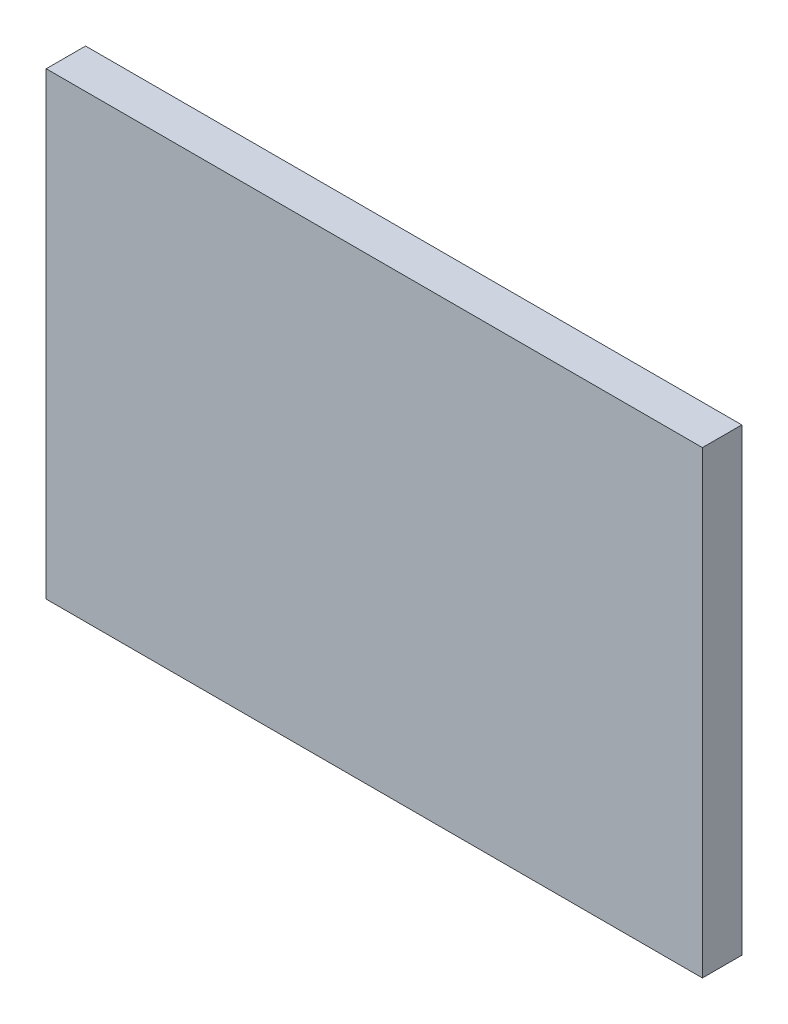
from build123d import *

# Parameters (mm, degrees)
SKETCH1_W           = 50
SKETCH1_H           = 35
BOSS_EXTRUDE1_DEPTH = 3


with BuildPart() as part:
    # Sketch1 → Boss-Extrude1 (new body)
    with BuildSketch(Plane.XY):
        Rectangle(SKETCH1_W, SKETCH1_H)
    extrude(amount=BOSS_EXTRUDE1_DEPTH)


solid = part.part
